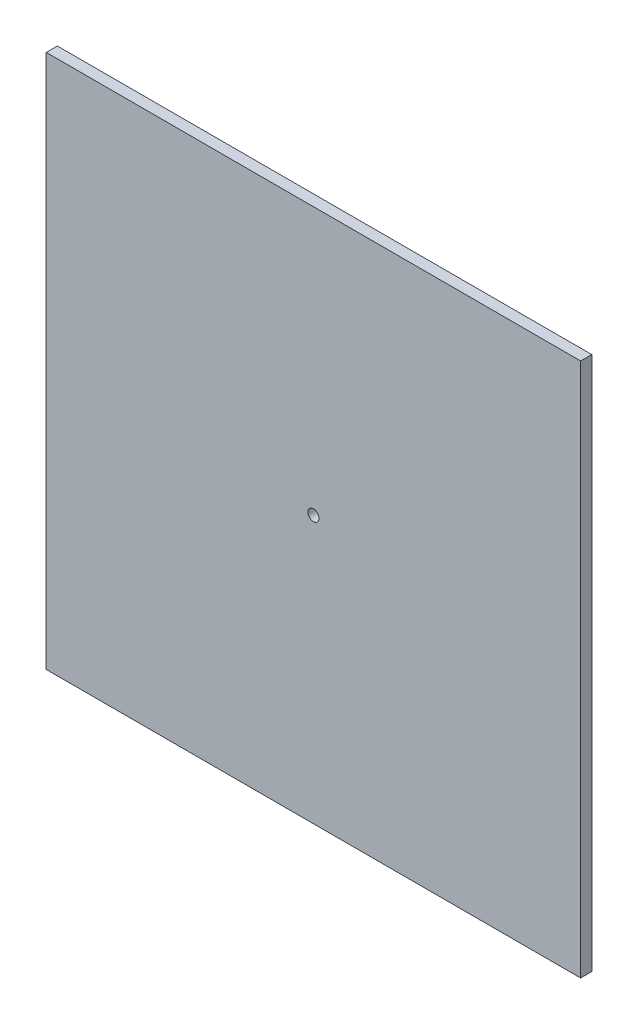
from build123d import *

# Parameters (mm, degrees)
SKETCH1_W                   = 304.8
SKETCH1_H                   = 304.8
BOSS_EXTRUDE1_DEPTH         = 6.35
F_1_4_0_25_DIAMETER_HOLE1_D = 6.35


with BuildPart() as part:
    # Sketch1 → Boss-Extrude1 (new body)
    with BuildSketch(Plane.XY):
        with Locations((-152.4, 152.4)):
            Rectangle(SKETCH1_W, SKETCH1_H)
    extrude(amount=BOSS_EXTRUDE1_DEPTH)

    # 1/4 (0.25) Diameter Hole1 (through all)
    with Locations(Plane.XY.offset(6.35)):
        with Locations((-152.4, 152.4)):
            Hole(F_1_4_0_25_DIAMETER_HOLE1_D / 2)


solid = part.part
